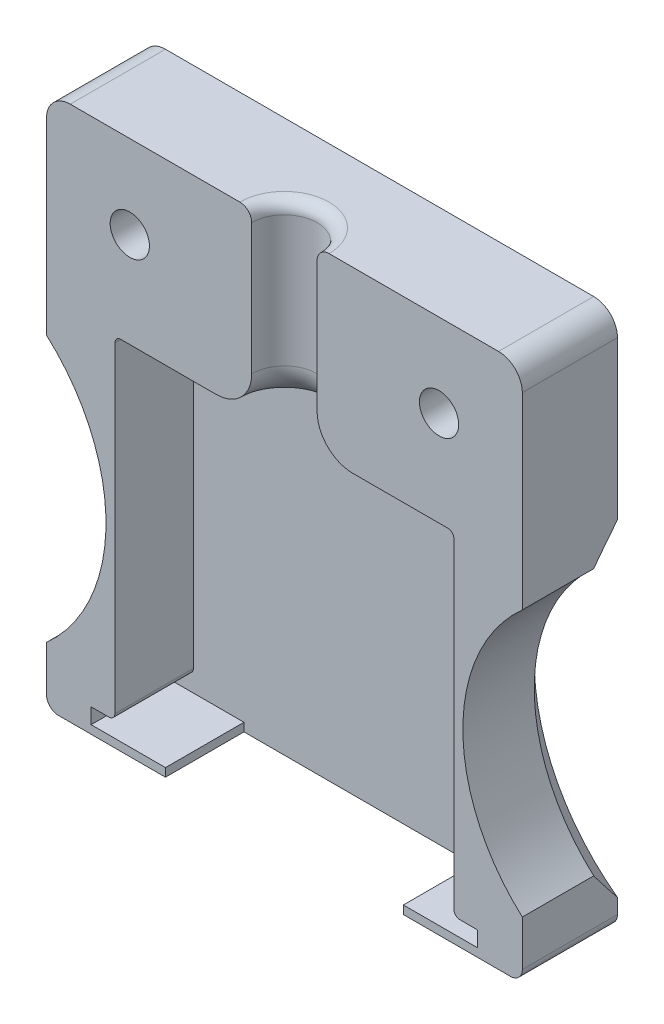
from build123d import *

# Parameters (mm, degrees)
CROQUIS1_W              = 40
CROQUIS1_H              = 45
SALIENTE_EXTRUIR1_DEPTH = 8
CROQUIS2_W              = 32.5
CROQUIS2_H              = 1.3
CORTAR_EXTRUIR1_DEPTH   = 6.6
CROQUIS3_R              = 15
CORTAR_EXTRUIR2_DEPTH   = 10
CHAFL_N1_SIZE           = 2
CROQUIS4_W              = 28.5
CROQUIS4_H              = 28
CORTAR_EXTRUIR3_DEPTH   = 6.6
CROQUIS6_R              = 2.75
CORTAR_EXTRUIR4_DEPTH   = 16.6
CROQUIS7_R              = 1.65
CORTAR_EXTRUIR5_DEPTH   = 16.6
CROQUIS8_R              = 4
CORTAR_EXTRUIR6_DEPTH   = 4
CROQUIS9_W              = 20
CROQUIS9_H              = 6.6
CORTAR_EXTRUIR7_DEPTH   = 4
REDONDEO1_R             = 1
REDONDEO2_R             = 2
REDONDEO3_R             = 1
REDONDEO4_R             = 3
REDONDEO5_R             = 0.5
REDONDEO6_R             = 0.5


with BuildPart() as part:
    # Croquis1 → Saliente-Extruir1 (new body)
    with BuildSketch(Plane.XY):
        Rectangle(CROQUIS1_W, CROQUIS1_H)
    extrude(amount=SALIENTE_EXTRUIR1_DEPTH)

    # Croquis2 → Cortar-Extruir1 (cut)
    with BuildSketch(Plane.XY.offset(8)):
        with Locations((0, -21.15)):
            Rectangle(CROQUIS2_W, CROQUIS2_H)
    extrude(amount=-CORTAR_EXTRUIR1_DEPTH, mode=Mode.SUBTRACT)

    # Croquis3 → Cortar-Extruir2 (cut)
    with BuildSketch(Plane.XY.offset(8)):
        with Locations((-30, -6.5)):
            Circle(CROQUIS3_R)
        with Locations((30, -6.5)):
            Circle(CROQUIS3_R)
    extrude(amount=-CORTAR_EXTRUIR2_DEPTH, mode=Mode.SUBTRACT)

    # Chaflán1
    chafl_n1_edges = [part.edges().sort_by_distance(p)[0] for p in [
        (-15, -6.5, 0),
        (15, -6.5, 0),
    ]]
    chamfer(chafl_n1_edges, length=CHAFL_N1_SIZE)

    # Croquis4 → Cortar-Extruir3 (cut)
    with BuildSketch(Plane.XY.offset(8)):
        with Locations((0, -6.5)):
            Rectangle(CROQUIS4_W, CROQUIS4_H)
    extrude(amount=-CORTAR_EXTRUIR3_DEPTH, mode=Mode.SUBTRACT)

    # Croquis6 → Cortar-Extruir4 (cut)
    with BuildSketch(Plane(origin=(0, 22.5, 0), x_dir=(1, 0, 0), z_dir=(0, 1, 0))):
        with Locations((0, -8)):
            Circle(CROQUIS6_R)
    extrude(amount=-CORTAR_EXTRUIR4_DEPTH, mode=Mode.SUBTRACT)

    # Croquis7 → Cortar-Extruir5 (cut)
    with BuildSketch(Plane.XY.offset(8)):
        with Locations((13, 15.5)):
            Circle(CROQUIS7_R)
        with Locations((-13, 15.5)):
            Circle(CROQUIS7_R)
    extrude(amount=-CORTAR_EXTRUIR5_DEPTH, mode=Mode.SUBTRACT)

    # Croquis8 → Cortar-Extruir6 (cut)
    with BuildSketch(Plane(origin=(0, 0, 0), x_dir=(-1, 0, 0), z_dir=(0, 0, -1))):
        with Locations((13, 15.5)):
            Circle(CROQUIS8_R)
        with Locations((-13, 15.5)):
            Circle(CROQUIS8_R)
    extrude(amount=-CORTAR_EXTRUIR6_DEPTH, mode=Mode.SUBTRACT)

    # Croquis9 → Cortar-Extruir7 (cut)
    with BuildSketch(Plane(origin=(0, -22.5, 0), x_dir=(-1, 0, 0), z_dir=(0, -1, 0))):
        with Locations((0, -4.7)):
            Rectangle(CROQUIS9_W, CROQUIS9_H)
    extrude(amount=-CORTAR_EXTRUIR7_DEPTH, mode=Mode.SUBTRACT)

    # Redondeo1
    redondeo1_edges = [part.edges().sort_by_distance(p)[0] for p in [
        (0, 22.5, 5.25),
    ]]
    fillet(redondeo1_edges, radius=REDONDEO1_R)

    # Redondeo2
    redondeo2_edges = [part.edges().sort_by_distance(p)[0] for p in [
        (-20, 22.5, 4),
        (20, 22.5, 4),
    ]]
    fillet(redondeo2_edges, radius=REDONDEO2_R)

    # Redondeo3
    redondeo3_edges = [part.edges().sort_by_distance(p)[0] for p in [
        (20, -22.5, 4),
        (-20, -22.5, 4),
    ]]
    fillet(redondeo3_edges, radius=REDONDEO3_R)

    # Redondeo4
    redondeo4_edges = [part.edges().sort_by_distance(p)[0] for p in [
        (0, 7.5, 5.25),
    ]]
    fillet(redondeo4_edges, radius=REDONDEO4_R)

    # Redondeo5
    redondeo5_edges = [part.edges().sort_by_distance(p)[0] for p in [
        (14.25, -20.5, 4.7),
        (-14.25, -20.5, 4.7),
    ]]
    fillet(redondeo5_edges, radius=REDONDEO5_R)

    # Redondeo6
    redondeo6_edges = [part.edges().sort_by_distance(p)[0] for p in [
        (-14.25, 7.5, 4.7),
        (14.25, 7.5, 4.7),
    ]]
    fillet(redondeo6_edges, radius=REDONDEO6_R)


solid = part.part
